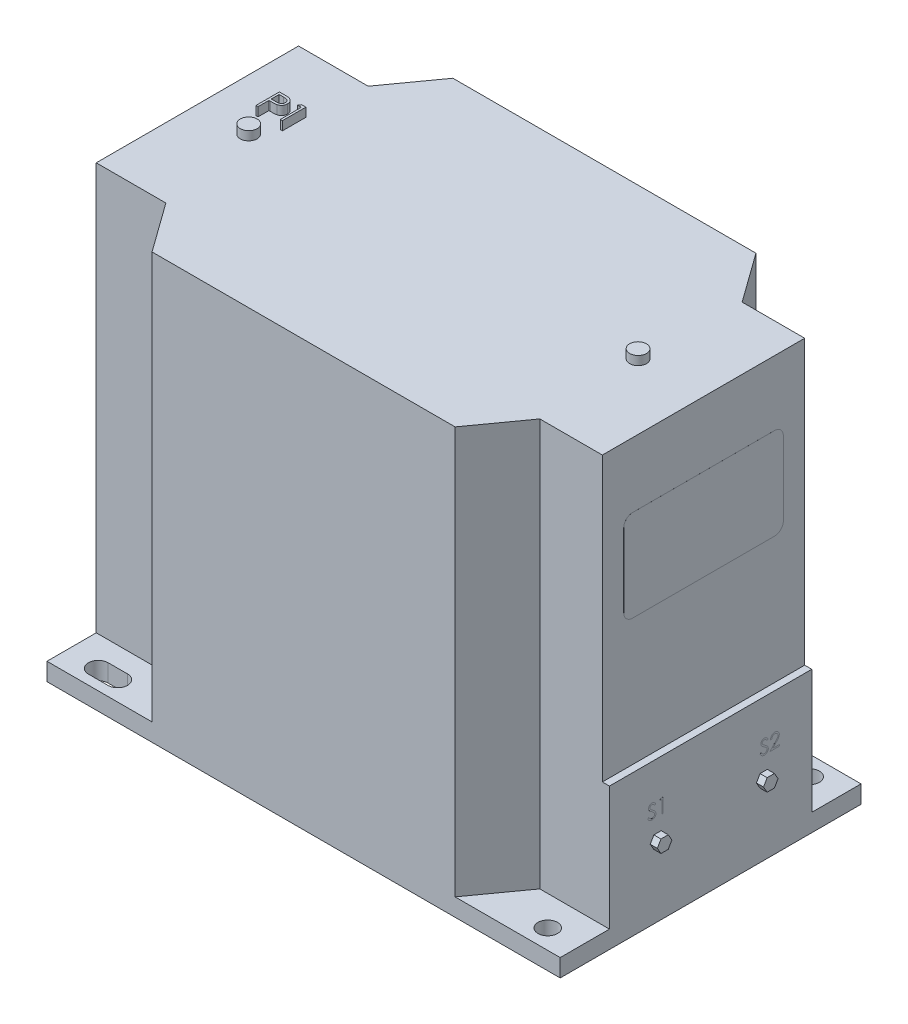
from build123d import *

# Parameters (mm, degrees)
CROQUIS1_W               = 290
CROQUIS1_H               = 170
SALIENTE_EXTRUIR1_DEPTH  = 240
CROQUIS2_R               = 5.5
CORTAR_EXTRUIR1_DEPTH    = 230
CROQUIS3_R               = 5.5
CORTAR_EXTRUIR3_DEPTH    = 309
CROQUIS4_W               = 114.318282822
CROQUIS4_H               = 160
CORTAR_EXTRUIR4_DEPTH    = 4
SALIENTE_EXTRUIR2_DEPTH  = 4
SALIENTE_EXTRUIR3_DEPTH  = 4
SALIENTE_EXTRUIR5_DEPTH  = 4
SALIENTE_EXTRUIR6_DEPTH  = 0.01
SALIENTE_EXTRUIR7_DEPTH  = 0.01
SALIENTE_EXTRUIR8_DEPTH  = 0.01
CROQUIS11_R              = 4.75
SALIENTE_EXTRUIR9_DEPTH  = 5
CROQUIS12_W              = 19.477537379
CROQUIS12_H              = 1.947753737
CROQUIS12_W_2            = 14.751875946
CROQUIS12_H_2            = 1.829107359
CROQUIS12_W_3            = 5.2253802
CROQUIS12_H_3            = 1.246064316
CROQUIS12_W_4            = 1.909821467
CROQUIS12_H_4            = 22.488415391
CROQUIS12_W_5            = 10.038203482
CROQUIS12_H_5            = 1.679080429
SALIENTE_EXTRUIR10_DEPTH = 0.1


with BuildPart() as part:
    # Croquis1 → Saliente-Extruir1 (new body)
    with BuildSketch(Plane(origin=(0, 0, 0), x_dir=(1, 0, 0), z_dir=(0, 1, 0))):
        Rectangle(CROQUIS1_W, CROQUIS1_H)
    extrude(amount=SALIENTE_EXTRUIR1_DEPTH)

    # Croquis2 → Cortar-Extruir1 (cut)
    with BuildSketch(Plane(origin=(0, 240, 0), x_dir=(1, 0, 0), z_dir=(0, 1, 0))):
        Polygon((-105.653068474, -57.159141411), (-145, -57.159141411), (-145, -85), (-85.626113794, -85), align=None)
        with BuildLine():
            Line((-116, -79.5), (-127, -79.5))
            ThreePointArc((-127, -79.5), (-132.5, -74), (-127, -68.5))
            Line((-127, -68.5), (-116, -68.5))
            ThreePointArc((-116, -68.5), (-110.5, -74), (-116, -79.5))
        make_face(mode=Mode.SUBTRACT)
        Polygon((-145, 85), (-145, 57.159141411), (-105.653068474, 57.159141411), (-85.626113794, 85), align=None)
        with BuildLine():
            ThreePointArc((-127, 68.5), (-132.5, 74), (-127, 79.5))
            Line((-127, 79.5), (-116, 79.5))
            ThreePointArc((-116, 79.5), (-110.5, 74), (-116, 68.5))
            Line((-116, 68.5), (-127, 68.5))
        make_face(mode=Mode.SUBTRACT)
        Polygon((145, 85), (85.626113794, 85), (105.653068474, 57.159141411), (145, 57.159141411), align=None)
        with Locations((127, 74)):
            Circle(CROQUIS2_R, mode=Mode.SUBTRACT)
        Polygon((105.653068474, -57.159141411), (85.626113794, -85), (145, -85), (145, -57.159141411), align=None)
        with Locations((127, -74)):
            Circle(CROQUIS2_R, mode=Mode.SUBTRACT)
    extrude(amount=-CORTAR_EXTRUIR1_DEPTH, mode=Mode.SUBTRACT)

    # Croquis3 → Cortar-Extruir3 (cut)
    with BuildSketch(Plane(origin=(0, 240, 0), x_dir=(1, 0, 0), z_dir=(0, 1, 0))):
        with Locations((127, 74)):
            Circle(CROQUIS3_R)
        with Locations((127, -74)):
            Circle(CROQUIS3_R)
        with BuildLine():
            Line((-127, 79.5), (-116, 79.5))
            ThreePointArc((-116, 79.5), (-110.5, 74), (-116, 68.5))
            Line((-116, 68.5), (-127, 68.5))
            ThreePointArc((-127, 68.5), (-132.5, 74), (-127, 79.5))
        make_face()
        with BuildLine():
            Line((-127, -68.426195021), (-116, -68.426195021))
            ThreePointArc((-116, -68.426195021), (-110.426195021, -74), (-116, -79.573804979))
            Line((-116, -79.573804979), (-127, -79.573804979))
            ThreePointArc((-127, -79.573804979), (-132.573804979, -74), (-127, -68.426195021))
        make_face()
    extrude(amount=-CORTAR_EXTRUIR3_DEPTH, mode=Mode.SUBTRACT)

    # Croquis4 → Cortar-Extruir4 (cut)
    with BuildSketch(Plane(origin=(145, 0, 0), x_dir=(0, 0, -1), z_dir=(1, 0, 0))):
        with Locations((0, 160)):
            Rectangle(CROQUIS4_W, CROQUIS4_H)
    extrude(amount=-CORTAR_EXTRUIR4_DEPTH, mode=Mode.SUBTRACT)

    # Croquis5 → Saliente-Extruir2 (add)
    with BuildSketch(Plane.ZY.offset(145)):
        Polygon((43.413866741, 29.419642397), (40.989340839, 33.619044445), (36.140289034, 33.619044445), (33.715763131, 29.419642397), (36.140289034, 25.220240349), (40.989340839, 25.220240349), align=None)
    extrude(amount=SALIENTE_EXTRUIR2_DEPTH)

    # Croquis6 → Saliente-Extruir3 (add)
    with BuildSketch(Plane.ZY.offset(145)):
        Polygon((43.413866741, 74.385865647), (40.989340839, 78.585267695), (36.140289034, 78.585267695), (33.715763131, 74.385865647), (36.140289034, 70.186463599), (40.989340839, 70.186463599), align=None)
    extrude(amount=SALIENTE_EXTRUIR3_DEPTH)

    # Croquis7 → Saliente-Extruir5 (add)
    with BuildSketch(Plane(origin=(145, 0, 0), x_dir=(0, 0, -1), z_dir=(1, 0, 0))):
        Polygon((-27.944874359, 36.440417974), (-32.055125641, 36.440417974), (-34.110251282, 40), (-32.055125641, 43.559582026), (-27.944874359, 43.559582026), (-25.889748718, 40), align=None)
        Polygon((34.110251282, 40), (32.055125641, 43.559582026), (27.944874359, 43.559582026), (25.889748718, 40), (27.944874359, 36.440417974), (32.055125641, 36.440417974), align=None)
    extrude(amount=SALIENTE_EXTRUIR5_DEPTH)

    # Croquis8 → Saliente-Extruir6 (add)
    with BuildSketch(Plane(origin=(145, 0, 0), x_dir=(0, 0, -1), z_dir=(1, 0, 0))):
        with BuildLine():
            Line((-35.585423462, 53.072879107), (-34.914424864, 53.475160256))
            add(Edge.make_bspline(
                [(-34.914424864, 53.475160256), (-34.852017433, 53.370692812), (-34.732447204, 53.17053722), (-34.532986086, 52.900077021), (-34.326309663, 52.67020213), (-34.110887424, 52.482249823), (-33.888034292, 52.33427467), (-33.656295455, 52.229494608), (-33.416451849, 52.164144093), (-33.253225504, 52.156206397), (-33.171736563, 52.15224359)],
                knots=[0, 0, 0, 0, 0.0003649, 0.000699135, 0.001006425, 0.001290478, 0.001554646, 0.001805858, 0.002050756, 0.002294909, 0.002294909, 0.002294909, 0.002294909], degree=3))
            add(Edge.make_bspline(
                [(-33.171736563, 52.15224359), (-33.102143147, 52.154181865), (-32.964174037, 52.1580245), (-32.761059665, 52.194947033), (-32.563797363, 52.251670968), (-32.376452774, 52.332907724), (-32.201610934, 52.431193218), (-32.048288607, 52.549906871), (-31.915741172, 52.682817373), (-31.80731693, 52.831095893), (-31.72413185, 52.990565141), (-31.660196266, 53.154249888), (-31.624715474, 53.324721462), (-31.619370694, 53.439498762), (-31.616673462, 53.497420873)],
                knots=[0, 0, 0, 0, 0.000208593, 0.000413536, 0.000617316, 0.000823176, 0.001024736, 0.001217466, 0.001402984, 0.001586171, 0.001766127, 0.001941248, 0.002111828, 0.002285609, 0.002285609, 0.002285609, 0.002285609], degree=3))
            add(Edge.make_bspline(
                [(-31.616673462, 53.497420873), (-31.620016988, 53.563508158), (-31.626813888, 53.697853949), (-31.684262066, 53.896063876), (-31.774634465, 54.092216669), (-31.858006889, 54.213549896), (-31.901291351, 54.276542468)],
                knots=[0, 0, 0, 0, 0.00019794, 0.000402383, 0.000614384, 0.000843289, 0.000843289, 0.000843289, 0.000843289], degree=3))
            add(Edge.make_bspline(
                [(-31.901291351, 54.276542468), (-31.936830065, 54.3220058), (-32.01143915, 54.417450379), (-32.139703509, 54.559520824), (-32.290212376, 54.706066167), (-32.45781508, 54.862682242), (-32.648616907, 55.022084924), (-32.856641806, 55.191875483), (-33.087200914, 55.365596917), (-33.248897987, 55.482102556), (-33.332331014, 55.542217548)],
                knots=[0, 0, 0, 0, 0.000173081, 0.000363362, 0.000573615, 0.000803155, 0.001051334, 0.001319279, 0.001608672, 0.001917177, 0.001917177, 0.001917177, 0.001917177], degree=3))
            add(Edge.make_bspline(
                [(-33.332331014, 55.542217548), (-33.415842577, 55.601700238), (-33.575510326, 55.715426611), (-33.798800325, 55.884210255), (-33.998472589, 56.038524031), (-34.173639645, 56.17982063), (-34.324224445, 56.308119215), (-34.451413609, 56.422187756), (-34.551967122, 56.525111189), (-34.607882457, 56.591879946), (-34.632987064, 56.621857472)],
                knots=[0, 0, 0, 0, 0.000307574, 0.000588058, 0.000839637, 0.001064621, 0.001263128, 0.001433085, 0.001577017, 0.001694292, 0.001694292, 0.001694292, 0.001694292], degree=3))
            add(Edge.make_bspline(
                [(-34.632987064, 56.621857472), (-34.668076586, 56.668577681), (-34.737084841, 56.760459241), (-34.828175603, 56.904070972), (-34.905598347, 57.051080877), (-34.966291493, 57.201883999), (-35.017400418, 57.354363212), (-35.05177644, 57.510508002), (-35.073301572, 57.669617726), (-35.075505899, 57.7766912), (-35.07660936, 57.830290966)],
                knots=[0, 0, 0, 0, 0.000175237, 0.000344627, 0.000509624, 0.000672912, 0.000831805, 0.000991507, 0.00115185, 0.00131257, 0.00131257, 0.00131257, 0.00131257], degree=3))
            add(Edge.make_bspline(
                [(-35.07660936, 57.830290966), (-35.073649332, 57.914269204), (-35.067792545, 58.080430706), (-35.018261372, 58.323161339), (-34.940081774, 58.554905535), (-34.830555868, 58.773368971), (-34.689365085, 58.972863249), (-34.525975108, 59.155683121), (-34.331366916, 59.309372584), (-34.117842217, 59.443657074), (-33.884125087, 59.548763012), (-33.639217145, 59.62804952), (-33.382729143, 59.672974087), (-33.209004177, 59.679421071), (-33.120855153, 59.682692308)],
                knots=[0, 0, 0, 0, 0.00025173, 0.000498079, 0.000739938, 0.000983843, 0.001228213, 0.001471329, 0.001716675, 0.001969492, 0.002226362, 0.002483325, 0.002740032, 0.003004458, 0.003004458, 0.003004458, 0.003004458], degree=3))
            add(Edge.make_bspline(
                [(-33.120855153, 59.682692308), (-33.027319425, 59.679466164), (-32.841306717, 59.673050394), (-32.567691532, 59.617266706), (-32.304255621, 59.524963397), (-32.092339646, 59.420214119), (-31.92648499, 59.315594659), (-31.8000004, 59.2202997), (-31.671826896, 59.110591864), (-31.540930593, 58.986178931), (-31.409529454, 58.845919335), (-31.275672696, 58.690773666), (-31.139047301, 58.521690048), (-31.051154547, 58.400984484), (-31.006096539, 58.339105068)],
                knots=[0, 0, 0, 0, 0.000280394, 0.000557614, 0.000833682, 0.001115986, 0.001264644, 0.001421423, 0.001590611, 0.00177056, 0.001962903, 0.002166931, 0.002385208, 0.002614814, 0.002614814, 0.002614814, 0.002614814], degree=3))
            Line((-31.006096539, 58.339105068), (-31.650064388, 57.850961538))
            add(Edge.make_bspline(
                [(-31.650064388, 57.850961538), (-31.688948913, 57.901055533), (-31.763831417, 57.997524854), (-31.877517932, 58.132624087), (-31.984671116, 58.256032889), (-32.090240773, 58.363223447), (-32.18865133, 58.460065785), (-32.284166765, 58.542978091), (-32.375412526, 58.612772745), (-32.490431234, 58.687257247), (-32.634933916, 58.761090746), (-32.816327418, 58.823568119), (-33.005889149, 58.861112635), (-33.13499742, 58.866076719), (-33.200357356, 58.868589744)],
                knots=[0, 0, 0, 0, 0.000190221, 0.000366322, 0.000529664, 0.000680341, 0.000817528, 0.000943773, 0.00105953, 0.001161851, 0.001354561, 0.001544636, 0.001735792, 0.001931781, 0.001931781, 0.001931781, 0.001931781], degree=3))
            add(Edge.make_bspline(
                [(-33.200357356, 58.868589744), (-33.282355184, 58.865841781), (-33.44048027, 58.860542595), (-33.664975984, 58.802666914), (-33.867028278, 58.711540195), (-34.04063856, 58.583825869), (-34.185184919, 58.43251219), (-34.289745513, 58.258388715), (-34.352678921, 58.066114337), (-34.36035852, 57.93198951), (-34.364269616, 57.863681891)],
                knots=[0, 0, 0, 0, 0.000245491, 0.000473406, 0.000690404, 0.000906674, 0.001115908, 0.001314154, 0.001511268, 0.001715841, 0.001715841, 0.001715841, 0.001715841], degree=3))
            add(Edge.make_bspline(
                [(-34.364269616, 57.863681891), (-34.363378061, 57.821156216), (-34.361593493, 57.73603533), (-34.33670422, 57.610279426), (-34.304728956, 57.48484121), (-34.254059059, 57.360284638), (-34.184106317, 57.23443136), (-34.092246364, 57.105114205), (-33.97655546, 56.971193366), (-33.887934378, 56.884090929), (-33.841145117, 56.838103466)],
                knots=[0, 0, 0, 0, 0.000127362, 0.000254933, 0.000383373, 0.000515356, 0.000656977, 0.000814464, 0.000990378, 0.001187139, 0.001187139, 0.001187139, 0.001187139], degree=3))
            add(Edge.make_bspline(
                [(-33.841145117, 56.838103466), (-33.823770219, 56.822598068), (-33.782491438, 56.785760792), (-33.707026392, 56.725453298), (-33.607370403, 56.651061297), (-33.486125768, 56.559015061), (-33.34105693, 56.452241031), (-33.172147937, 56.332104446), (-32.981281603, 56.19470528), (-32.84584083, 56.098644429), (-32.774225545, 56.047851563)],
                knots=[0, 0, 0, 0, 6.9853e-05, 0.000165956, 0.000289663, 0.000442943, 0.000622625, 0.000830015, 0.001064761, 0.001328157, 0.001328157, 0.001328157, 0.001328157], degree=3))
            add(Edge.make_bspline(
                [(-32.774225545, 56.047851563), (-32.688078921, 55.985164908), (-32.521267921, 55.863780889), (-32.283919481, 55.681409615), (-32.068713881, 55.503047711), (-31.874895544, 55.329834209), (-31.700549698, 55.163082998), (-31.547610582, 55.000787929), (-31.414519842, 54.844111719), (-31.2712384, 54.643241771), (-31.124830488, 54.396541812), (-30.99909707, 54.094285807), (-30.919816532, 53.790854865), (-30.909448988, 53.586913647), (-30.904333719, 53.486290565)],
                knots=[0, 0, 0, 0, 0.000319615, 0.00061889, 0.000897801, 0.001157932, 0.001398581, 0.001621301, 0.001826718, 0.0020147, 0.002361038, 0.002684673, 0.002994344, 0.003295938, 0.003295938, 0.003295938, 0.003295938], degree=3))
            add(Edge.make_bspline(
                [(-30.904333719, 53.486290565), (-30.905824014, 53.415128915), (-30.908775664, 53.274187528), (-30.942704879, 53.06723405), (-30.992415549, 52.866231899), (-31.067339276, 52.673665626), (-31.158786438, 52.486012325), (-31.274824179, 52.308194408), (-31.409325535, 52.136276326), (-31.563616395, 51.974842336), (-31.732449066, 51.826646499), (-31.910892445, 51.694818092), (-32.0992386, 51.584898858), (-32.296465782, 51.495203199), (-32.502619296, 51.4250504), (-32.717629806, 51.374221215), (-32.941851733, 51.343025227), (-33.094252825, 51.339787268), (-33.171736563, 51.338141026)],
                knots=[0, 0, 0, 0, 0.000213279, 0.000422417, 0.000627582, 0.000833411, 0.001041051, 0.00125276, 0.001469058, 0.001695119, 0.001921581, 0.002142294, 0.002359642, 0.002574533, 0.002791252, 0.003011856, 0.003236503, 0.003468846, 0.003468846, 0.003468846, 0.003468846], degree=3))
            add(Edge.make_bspline(
                [(-33.171736563, 51.338141026), (-33.231688144, 51.339300312), (-33.350836279, 51.341604286), (-33.527070282, 51.361972547), (-33.699743994, 51.390790443), (-33.866690669, 51.436542351), (-34.030061227, 51.492052639), (-34.189145134, 51.560402072), (-34.344019489, 51.642310725), (-34.495552221, 51.735961941), (-34.643357939, 51.844950041), (-34.786050303, 51.971889934), (-34.928311135, 52.113280633), (-35.06594148, 52.272961732), (-35.201725218, 52.448353456), (-35.332985182, 52.641096782), (-35.462438364, 52.850141853), (-35.543662728, 52.997246601), (-35.585423462, 53.072879107)],
                knots=[0, 0, 0, 0, 0.000179788, 0.000357311, 0.000531673, 0.000704462, 0.000875929, 0.00104901, 0.001223263, 0.001401078, 0.001582983, 0.001773397, 0.001973528, 0.002184286, 0.002405325, 0.002638633, 0.002883531, 0.003142684, 0.003142684, 0.003142684, 0.003142684], degree=3))
        make_face()
        Polygon((-28.301431575, 59.479166667), (-26.833820898, 59.479166667), (-26.833820898, 51.541666667), (-27.546160642, 51.541666667), (-27.546160642, 58.665064103), (-28.767314488, 58.665064103), align=None)
        with BuildLine():
            Line((27.914576538, 53.072879107), (28.585575136, 53.475160256))
            add(Edge.make_bspline(
                [(28.585575136, 53.475160256), (28.647982567, 53.370692812), (28.767552796, 53.17053722), (28.967013914, 52.900077021), (29.173690337, 52.67020213), (29.389112576, 52.482249823), (29.611965708, 52.33427467), (29.843704545, 52.229494608), (30.083548151, 52.164144093), (30.246774496, 52.156206397), (30.328263437, 52.15224359)],
                knots=[0, 0, 0, 0, 0.0003649, 0.000699135, 0.001006425, 0.001290478, 0.001554646, 0.001805858, 0.002050756, 0.002294909, 0.002294909, 0.002294909, 0.002294909], degree=3))
            add(Edge.make_bspline(
                [(30.328263437, 52.15224359), (30.397856853, 52.154181865), (30.535825963, 52.1580245), (30.738940335, 52.194947033), (30.936202637, 52.251670968), (31.123547226, 52.332907724), (31.298389066, 52.431193218), (31.451711393, 52.549906871), (31.584258828, 52.682817373), (31.69268307, 52.831095893), (31.77586815, 52.990565141), (31.839803734, 53.154249888), (31.875284526, 53.324721462), (31.880629306, 53.439498762), (31.883326538, 53.497420873)],
                knots=[0, 0, 0, 0, 0.000208593, 0.000413536, 0.000617316, 0.000823176, 0.001024736, 0.001217466, 0.001402984, 0.001586171, 0.001766127, 0.001941248, 0.002111828, 0.002285609, 0.002285609, 0.002285609, 0.002285609], degree=3))
            add(Edge.make_bspline(
                [(31.883326538, 53.497420873), (31.879983012, 53.563508158), (31.873186112, 53.697853949), (31.815737934, 53.896063876), (31.725365535, 54.092216669), (31.641993111, 54.213549896), (31.598708649, 54.276542468)],
                knots=[0, 0, 0, 0, 0.00019794, 0.000402383, 0.000614384, 0.000843289, 0.000843289, 0.000843289, 0.000843289], degree=3))
            add(Edge.make_bspline(
                [(31.598708649, 54.276542468), (31.563169935, 54.3220058), (31.48856085, 54.417450379), (31.360296491, 54.559520824), (31.209787624, 54.706066167), (31.04218492, 54.862682242), (30.851383093, 55.022084924), (30.643358194, 55.191875483), (30.412799086, 55.365596917), (30.251102013, 55.482102556), (30.167668986, 55.542217548)],
                knots=[0, 0, 0, 0, 0.000173081, 0.000363362, 0.000573615, 0.000803155, 0.001051334, 0.001319279, 0.001608672, 0.001917177, 0.001917177, 0.001917177, 0.001917177], degree=3))
            add(Edge.make_bspline(
                [(30.167668986, 55.542217548), (30.084157423, 55.601700238), (29.924489674, 55.715426611), (29.701199675, 55.884210255), (29.501527411, 56.038524031), (29.326360355, 56.17982063), (29.175775555, 56.308119215), (29.048586391, 56.422187756), (28.948032878, 56.525111189), (28.892117543, 56.591879946), (28.867012936, 56.621857472)],
                knots=[0, 0, 0, 0, 0.000307574, 0.000588058, 0.000839637, 0.001064621, 0.001263128, 0.001433085, 0.001577017, 0.001694292, 0.001694292, 0.001694292, 0.001694292], degree=3))
            add(Edge.make_bspline(
                [(28.867012936, 56.621857472), (28.831923414, 56.668577681), (28.762915159, 56.760459241), (28.671824397, 56.904070972), (28.594401653, 57.051080877), (28.533708507, 57.201883999), (28.482599582, 57.354363212), (28.44822356, 57.510508002), (28.426698428, 57.669617726), (28.424494101, 57.7766912), (28.42339064, 57.830290966)],
                knots=[0, 0, 0, 0, 0.000175237, 0.000344627, 0.000509624, 0.000672912, 0.000831805, 0.000991507, 0.00115185, 0.00131257, 0.00131257, 0.00131257, 0.00131257], degree=3))
            add(Edge.make_bspline(
                [(28.42339064, 57.830290966), (28.426350668, 57.914269204), (28.432207455, 58.080430706), (28.481738628, 58.323161339), (28.559918226, 58.554905535), (28.669444132, 58.773368971), (28.810634915, 58.972863249), (28.974024892, 59.155683121), (29.168633084, 59.309372584), (29.382157783, 59.443657074), (29.615874913, 59.548763012), (29.860782855, 59.62804952), (30.117270857, 59.672974087), (30.290995823, 59.679421071), (30.379144847, 59.682692308)],
                knots=[0, 0, 0, 0, 0.00025173, 0.000498079, 0.000739938, 0.000983843, 0.001228213, 0.001471329, 0.001716675, 0.001969492, 0.002226362, 0.002483325, 0.002740032, 0.003004458, 0.003004458, 0.003004458, 0.003004458], degree=3))
            add(Edge.make_bspline(
                [(30.379144847, 59.682692308), (30.472680575, 59.679466164), (30.658693283, 59.673050394), (30.932308468, 59.617266706), (31.195744379, 59.524963397), (31.407660354, 59.420214119), (31.57351501, 59.315594659), (31.6999996, 59.2202997), (31.828173104, 59.110591864), (31.959069407, 58.986178931), (32.090470546, 58.845919335), (32.224327304, 58.690773666), (32.360952699, 58.521690048), (32.448845453, 58.400984484), (32.493903461, 58.339105068)],
                knots=[0, 0, 0, 0, 0.000280394, 0.000557614, 0.000833682, 0.001115986, 0.001264644, 0.001421423, 0.001590611, 0.00177056, 0.001962903, 0.002166931, 0.002385208, 0.002614814, 0.002614814, 0.002614814, 0.002614814], degree=3))
            Line((32.493903461, 58.339105068), (31.849935612, 57.850961538))
            add(Edge.make_bspline(
                [(31.849935612, 57.850961538), (31.811051087, 57.901055533), (31.736168583, 57.997524854), (31.622482068, 58.132624087), (31.515328884, 58.256032889), (31.409759227, 58.363223447), (31.31134867, 58.460065785), (31.215833235, 58.542978091), (31.124587474, 58.612772745), (31.009568766, 58.687257247), (30.865066084, 58.761090746), (30.683672582, 58.823568119), (30.494110851, 58.861112635), (30.36500258, 58.866076719), (30.299642644, 58.868589744)],
                knots=[0, 0, 0, 0, 0.000190221, 0.000366322, 0.000529664, 0.000680341, 0.000817528, 0.000943773, 0.00105953, 0.001161851, 0.001354561, 0.001544636, 0.001735792, 0.001931781, 0.001931781, 0.001931781, 0.001931781], degree=3))
            add(Edge.make_bspline(
                [(30.299642644, 58.868589744), (30.217644816, 58.865841781), (30.05951973, 58.860542595), (29.835024016, 58.802666914), (29.632971722, 58.711540195), (29.45936144, 58.583825869), (29.314815081, 58.43251219), (29.210254487, 58.258388715), (29.147321079, 58.066114337), (29.13964148, 57.93198951), (29.135730384, 57.863681891)],
                knots=[0, 0, 0, 0, 0.000245491, 0.000473406, 0.000690404, 0.000906674, 0.001115908, 0.001314154, 0.001511268, 0.001715841, 0.001715841, 0.001715841, 0.001715841], degree=3))
            add(Edge.make_bspline(
                [(29.135730384, 57.863681891), (29.136621939, 57.821156216), (29.138406507, 57.73603533), (29.16329578, 57.610279426), (29.195271044, 57.48484121), (29.245940941, 57.360284638), (29.315893683, 57.23443136), (29.407753636, 57.105114205), (29.52344454, 56.971193366), (29.612065622, 56.884090929), (29.658854883, 56.838103466)],
                knots=[0, 0, 0, 0, 0.000127362, 0.000254933, 0.000383373, 0.000515356, 0.000656977, 0.000814464, 0.000990378, 0.001187139, 0.001187139, 0.001187139, 0.001187139], degree=3))
            add(Edge.make_bspline(
                [(29.658854883, 56.838103466), (29.676229781, 56.822598068), (29.717508562, 56.785760792), (29.792973608, 56.725453298), (29.892629597, 56.651061297), (30.013874232, 56.559015061), (30.15894307, 56.452241031), (30.327852063, 56.332104446), (30.518718397, 56.19470528), (30.65415917, 56.098644429), (30.725774455, 56.047851563)],
                knots=[0, 0, 0, 0, 6.9853e-05, 0.000165956, 0.000289663, 0.000442943, 0.000622625, 0.000830015, 0.001064761, 0.001328157, 0.001328157, 0.001328157, 0.001328157], degree=3))
            add(Edge.make_bspline(
                [(30.725774455, 56.047851563), (30.811921079, 55.985164908), (30.978732079, 55.863780889), (31.216080519, 55.681409615), (31.431286119, 55.503047711), (31.625104456, 55.329834209), (31.799450302, 55.163082998), (31.952389418, 55.000787929), (32.085480158, 54.844111719), (32.2287616, 54.643241771), (32.375169512, 54.396541812), (32.50090293, 54.094285807), (32.580183468, 53.790854865), (32.590551012, 53.586913647), (32.595666281, 53.486290565)],
                knots=[0, 0, 0, 0, 0.000319615, 0.00061889, 0.000897801, 0.001157932, 0.001398581, 0.001621301, 0.001826718, 0.0020147, 0.002361038, 0.002684673, 0.002994344, 0.003295938, 0.003295938, 0.003295938, 0.003295938], degree=3))
            add(Edge.make_bspline(
                [(32.595666281, 53.486290565), (32.594175986, 53.415128915), (32.591224336, 53.274187528), (32.557295121, 53.06723405), (32.507584451, 52.866231899), (32.432660724, 52.673665626), (32.341213562, 52.486012325), (32.225175821, 52.308194408), (32.090674465, 52.136276326), (31.936383605, 51.974842336), (31.767550934, 51.826646499), (31.589107555, 51.694818092), (31.4007614, 51.584898858), (31.203534218, 51.495203199), (30.997380704, 51.4250504), (30.782370194, 51.374221215), (30.558148267, 51.343025227), (30.405747175, 51.339787268), (30.328263437, 51.338141026)],
                knots=[0, 0, 0, 0, 0.000213279, 0.000422417, 0.000627582, 0.000833411, 0.001041051, 0.00125276, 0.001469058, 0.001695119, 0.001921581, 0.002142294, 0.002359642, 0.002574533, 0.002791252, 0.003011856, 0.003236503, 0.003468846, 0.003468846, 0.003468846, 0.003468846], degree=3))
            add(Edge.make_bspline(
                [(30.328263437, 51.338141026), (30.268311856, 51.339300312), (30.149163721, 51.341604286), (29.972929718, 51.361972547), (29.800256006, 51.390790443), (29.633309331, 51.436542351), (29.469938773, 51.492052639), (29.310854866, 51.560402072), (29.155980511, 51.642310725), (29.004447779, 51.735961941), (28.856642061, 51.844950041), (28.713949697, 51.971889934), (28.571688865, 52.113280633), (28.43405852, 52.272961732), (28.298274782, 52.448353456), (28.167014818, 52.641096782), (28.037561636, 52.850141853), (27.956337272, 52.997246601), (27.914576538, 53.072879107)],
                knots=[0, 0, 0, 0, 0.000179788, 0.000357311, 0.000531673, 0.000704462, 0.000875929, 0.00104901, 0.001223263, 0.001401078, 0.001582983, 0.001773397, 0.001973528, 0.002184286, 0.002405325, 0.002638633, 0.002883531, 0.003142684, 0.003142684, 0.003142684, 0.003142684], degree=3))
        make_face()
        with BuildLine():
            Line((34.529159871, 57.036858974), (33.816820128, 57.036858974))
            add(Edge.make_bspline(
                [(33.816820128, 57.036858974), (33.821462778, 57.131362595), (33.83058082, 57.31696519), (33.873280691, 57.587574764), (33.934378751, 57.846234754), (34.020764728, 58.090868309), (34.128048607, 58.323638461), (34.256704205, 58.543620639), (34.409090259, 58.749975657), (34.581916245, 58.940790533), (34.769623695, 59.115840917), (34.972156807, 59.267005486), (35.184983923, 59.394725919), (35.407459345, 59.501499449), (35.642093123, 59.581645171), (35.886756033, 59.641112104), (36.142523003, 59.676890602), (36.316785196, 59.680736402), (36.405411874, 59.682692308)],
                knots=[0, 0, 0, 0, 0.00028367, 0.000557121, 0.000820522, 0.001080006, 0.001333985, 0.001588417, 0.001843152, 0.0021021, 0.00235977, 0.002611952, 0.002858736, 0.003103402, 0.003350806, 0.003601095, 0.003857896, 0.004123666, 0.004123666, 0.004123666, 0.004123666], degree=3))
            add(Edge.make_bspline(
                [(36.405411874, 59.682692308), (36.492447864, 59.680654737), (36.663470474, 59.676650983), (36.9130754, 59.642267934), (37.150695335, 59.588416325), (37.375865806, 59.51286172), (37.586790274, 59.411297036), (37.78505325, 59.289291904), (37.973015089, 59.148186215), (38.142212616, 58.982057031), (38.297579153, 58.804705195), (38.431614624, 58.615366556), (38.546398048, 58.419810855), (38.642073679, 58.216546897), (38.712504566, 58.003660815), (38.765976573, 57.78425198), (38.796201244, 57.556049284), (38.800839972, 57.401593345), (38.803198333, 57.323066907)],
                knots=[0, 0, 0, 0, 0.000261005, 0.000512865, 0.000754321, 0.000991152, 0.001223718, 0.001454969, 0.001688711, 0.001927112, 0.002164944, 0.002395254, 0.002621873, 0.002844536, 0.003067789, 0.003293401, 0.0035212, 0.003756789, 0.003756789, 0.003756789, 0.003756789], degree=3))
            add(Edge.make_bspline(
                [(38.803198333, 57.323066907), (38.799358255, 57.212513782), (38.791745486, 56.993347583), (38.726625382, 56.671278162), (38.624919901, 56.359235944), (38.50246161, 56.108099563), (38.378925889, 55.905730746), (38.267602434, 55.739114219), (38.137280452, 55.559714318), (37.986063144, 55.368131785), (37.817078595, 55.162865982), (37.628796188, 54.94404091), (37.419873292, 54.713917432), (37.273237049, 54.556742229), (37.197253822, 54.475297977)],
                knots=[0, 0, 0, 0, 0.000331374, 0.000656934, 0.000981755, 0.001313861, 0.001492201, 0.001692855, 0.001914853, 0.002157229, 0.002424948, 0.002712447, 0.003023161, 0.003357316, 0.003357316, 0.003357316, 0.003357316], degree=3))
            Line((37.197253822, 54.475297977), (35.211288777, 52.355769231))
            Line((35.211288777, 52.355769231), (38.904961153, 52.355769231))
            Line((38.904961153, 52.355769231), (38.904961153, 51.541666667))
            Line((38.904961153, 51.541666667), (33.511531666, 51.541666667))
            Line((33.511531666, 51.541666667), (36.589856987, 54.826697716))
            add(Edge.make_bspline(
                [(36.589856987, 54.826697716), (36.664804873, 54.904934947), (36.808764424, 55.055212656), (37.012378482, 55.274611869), (37.195256187, 55.478151006), (37.358581346, 55.6654455), (37.498810903, 55.839234949), (37.623253286, 55.993890794), (37.722960965, 56.136208923), (37.831172666, 56.301174243), (37.935979374, 56.502587891), (38.026041325, 56.748726794), (38.080957142, 57.002108242), (38.087544893, 57.173336076), (38.090858589, 57.259465144)],
                knots=[0, 0, 0, 0, 0.000325027, 0.00062431, 0.000897913, 0.001145919, 0.00136967, 0.001567839, 0.00174122, 0.001890735, 0.00215956, 0.002420114, 0.002675206, 0.002933386, 0.002933386, 0.002933386, 0.002933386], degree=3))
            add(Edge.make_bspline(
                [(38.090858589, 57.259465144), (38.089416816, 57.313624744), (38.086575359, 57.420362916), (38.061498081, 57.576858119), (38.02360104, 57.727817608), (37.969296616, 57.873705726), (37.897617045, 58.013055687), (37.810364915, 58.146037115), (37.709694593, 58.27459959), (37.59323725, 58.395143676), (37.465303982, 58.505545696), (37.330152737, 58.603344961), (37.187164108, 58.685076516), (37.036940974, 58.752076947), (36.879902141, 58.804635401), (36.71574388, 58.841053965), (36.544919772, 58.863919598), (36.428275951, 58.867013345), (36.368840861, 58.868589744)],
                knots=[0, 0, 0, 0, 0.000162379, 0.000320018, 0.000474277, 0.000628741, 0.000785898, 0.000943344, 0.001105256, 0.001275063, 0.001445287, 0.001611643, 0.001774744, 0.001938449, 0.002104379, 0.002270635, 0.00244222, 0.002620482, 0.002620482, 0.002620482, 0.002620482], degree=3))
            add(Edge.make_bspline(
                [(36.368840861, 58.868589744), (36.306767722, 58.866968153), (36.184866327, 58.863783616), (36.005889235, 58.841507217), (35.835151846, 58.803076472), (35.672224674, 58.750515085), (35.516832041, 58.683707305), (35.369729656, 58.600495669), (35.231247746, 58.501200962), (35.101125988, 58.388623272), (34.981238036, 58.263284247), (34.875903156, 58.123561653), (34.78386441, 57.972006621), (34.703561327, 57.809028087), (34.63834753, 57.633147193), (34.588515564, 57.444988291), (34.549084679, 57.245368372), (34.535911784, 57.107516483), (34.529159871, 57.036858974)],
                knots=[0, 0, 0, 0, 0.000186205, 0.000365676, 0.000540038, 0.000710499, 0.000878571, 0.001046604, 0.001216471, 0.001388938, 0.001562143, 0.001735779, 0.00191276, 0.002093382, 0.002280042, 0.002474444, 0.00267683, 0.002889646, 0.002889646, 0.002889646, 0.002889646], degree=3))
        make_face()
    extrude(amount=SALIENTE_EXTRUIR6_DEPTH)

    # Croquis9 → Saliente-Extruir7 (add)
    with BuildSketch(Plane.ZY.offset(145)):
        with BuildLine():
            Line((31.885683761, 114.9375), (34.480105669, 114.9375))
            add(Edge.make_bspline(
                [(34.480105669, 114.9375), (34.658551654, 114.937303845), (35.000462085, 114.936928002), (35.490754111, 114.925532981), (35.936046846, 114.910313043), (36.335380131, 114.889214816), (36.689982645, 114.864281275), (36.998249819, 114.829310769), (37.26260469, 114.792797152), (37.421001091, 114.755674574), (37.493239183, 114.738744491)],
                knots=[0, 0, 0, 0, 0.000535321, 0.0010257, 0.001471196, 0.001871918, 0.002225373, 0.002537339, 0.002802691, 0.003025171, 0.003025171, 0.003025171, 0.003025171], degree=3))
            add(Edge.make_bspline(
                [(37.493239183, 114.738744491), (37.58468498, 114.713715097), (37.765421769, 114.664246096), (38.025851307, 114.565164463), (38.273629235, 114.447681279), (38.509605661, 114.313787221), (38.730880796, 114.157737618), (38.940756011, 113.98585817), (39.137379151, 113.794180515), (39.319644531, 113.584854504), (39.487030521, 113.361394187), (39.631151644, 113.120463735), (39.75182896, 112.86611863), (39.855331206, 112.598535786), (39.929824472, 112.315468195), (39.985942218, 112.018882704), (40.021561286, 111.708811107), (40.024972755, 111.496918156), (40.026709402, 111.389051649)],
                knots=[0, 0, 0, 0, 0.0002843, 0.000561901, 0.000834549, 0.001106385, 0.001374724, 0.001645836, 0.001919449, 0.002197416, 0.002477798, 0.002755942, 0.003038048, 0.003321544, 0.003615331, 0.003914708, 0.004226674, 0.004550157, 0.004550157, 0.004550157, 0.004550157], degree=3))
            add(Edge.make_bspline(
                [(40.026709402, 111.389051649), (40.025116517, 111.280278505), (40.021999929, 111.067456501), (39.984594327, 110.756106975), (39.934209376, 110.458570202), (39.856735399, 110.17550591), (39.755265146, 109.908595111), (39.636232685, 109.653758907), (39.492663984, 109.415332766), (39.327696919, 109.192451102), (39.144183452, 108.984904707), (38.942900025, 108.794197597), (38.724659247, 108.621446079), (38.490154699, 108.466262876), (38.237100211, 108.332246581), (37.969333738, 108.21221153), (37.68452786, 108.111401271), (37.487441572, 108.058370979), (37.387236245, 108.031408587)],
                knots=[0, 0, 0, 0, 0.000326131, 0.000638098, 0.000939601, 0.001230832, 0.001516807, 0.00179538, 0.002073524, 0.0023502, 0.002626177, 0.002903613, 0.00318091, 0.003460213, 0.003745955, 0.004038976, 0.004339885, 0.004651119, 0.004651119, 0.004651119, 0.004651119], degree=3))
            add(Edge.make_bspline(
                [(37.387236245, 108.031408587), (37.304356143, 108.013783629), (37.122719581, 107.975157508), (36.823578935, 107.932036258), (36.475291315, 107.895230445), (36.078332103, 107.867633884), (35.633057611, 107.844008979), (35.139226966, 107.825230767), (34.595870781, 107.81491257), (34.216869353, 107.814380406), (34.018992889, 107.814102564)],
                knots=[0, 0, 0, 0, 0.000254145, 0.000556973, 0.000906109, 0.001304688, 0.001750538, 0.002243801, 0.00278717, 0.003380792, 0.003380792, 0.003380792, 0.003380792], degree=3))
            Line((34.018992889, 107.814102564), (33.072916667, 107.814102564))
            Line((33.072916667, 107.814102564), (33.072916667, 101.708333333))
            Line((33.072916667, 101.708333333), (31.885683761, 101.708333333))
            Line((31.885683761, 101.708333333), (31.885683761, 114.9375))
        make_face()
        with BuildLine():
            Line((33.072916667, 113.580662393), (33.072916667, 109.170940171))
            Line((33.072916667, 109.170940171), (35.389080863, 109.141789363))
            add(Edge.make_bspline(
                [(35.389080863, 109.141789363), (35.502171058, 109.141730914), (35.72048935, 109.14161808), (36.035858408, 109.156681276), (36.328447083, 109.174070194), (36.597356639, 109.199530381), (36.842708296, 109.235518468), (37.064911158, 109.271848548), (37.262242257, 109.324407508), (37.493182692, 109.395176252), (37.750521536, 109.515873936), (38.030479234, 109.691065485), (38.267737105, 109.914376495), (38.473047334, 110.165457881), (38.635977289, 110.444778995), (38.755251427, 110.74364075), (38.825332587, 111.058978157), (38.834729807, 111.27475773), (38.839476496, 111.383751502)],
                knots=[0, 0, 0, 0, 0.00033922, 0.000654857, 0.000946954, 0.001218558, 0.001464787, 0.001690914, 0.00189338, 0.002076926, 0.002414901, 0.00274275, 0.003063453, 0.003387521, 0.003712952, 0.004029378, 0.004349588, 0.004676418, 0.004676418, 0.004676418, 0.004676418], degree=3))
            add(Edge.make_bspline(
                [(38.839476496, 111.383751502), (38.834703993, 111.490108384), (38.825216847, 111.7015327), (38.754702126, 112.011392896), (38.636209184, 112.307105231), (38.471953603, 112.58292612), (38.27260469, 112.833104039), (38.040907768, 113.05042949), (37.777408238, 113.225136521), (37.532297365, 113.337899222), (37.314578596, 113.406748627), (37.1254697, 113.454921089), (36.911948401, 113.493382458), (36.673945187, 113.524525817), (36.413304773, 113.551186221), (36.127787928, 113.569276075), (35.818476241, 113.579864913), (35.603745809, 113.58039013), (35.492433727, 113.580662393)],
                knots=[0, 0, 0, 0, 0.000318902, 0.000633938, 0.000947901, 0.001271047, 0.001593454, 0.001904722, 0.002220036, 0.002537835, 0.002710477, 0.002904584, 0.00312289, 0.003360881, 0.003624573, 0.003908737, 0.004218977, 0.004552896, 0.004552896, 0.004552896, 0.004552896], degree=3))
            Line((35.492433727, 113.580662393), (33.072916667, 113.580662393))
        make_face(mode=Mode.SUBTRACT)
        with BuildLine():
            Line((43.249198718, 110.866987179), (42.061965812, 110.866987179))
            add(Edge.make_bspline(
                [(42.061965812, 110.866987179), (42.069703563, 111.024493214), (42.0849003, 111.333830873), (42.15606675, 111.784846829), (42.257896852, 112.215946812), (42.401873478, 112.623669403), (42.580679945, 113.011619657), (42.795105941, 113.378256621), (43.049082698, 113.72218165), (43.337126008, 114.040206444), (43.649971757, 114.331957084), (43.987526945, 114.583898031), (44.342238804, 114.79676542), (44.713031175, 114.974721305), (45.104087472, 115.108297508), (45.511858988, 115.207409062), (45.938137271, 115.267039893), (46.228574259, 115.273449559), (46.37628539, 115.276709402)],
                knots=[0, 0, 0, 0, 0.000472784, 0.000928535, 0.001367536, 0.00180001, 0.002223309, 0.002647362, 0.00307192, 0.0035035, 0.003932951, 0.004353253, 0.004764561, 0.005172336, 0.005584676, 0.006001825, 0.006429826, 0.006872777, 0.006872777, 0.006872777, 0.006872777], degree=3))
            add(Edge.make_bspline(
                [(46.37628539, 115.276709402), (46.521345372, 115.27331345), (46.806383056, 115.266640527), (47.222391265, 115.209335446), (47.618424492, 115.119582763), (47.993708609, 114.993658422), (48.345249389, 114.824383949), (48.675687682, 114.621042062), (48.988957413, 114.385865914), (49.270953292, 114.10898394), (49.52989752, 113.813397547), (49.753289973, 113.497833149), (49.94459568, 113.17190698), (50.104055065, 112.833133718), (50.221439876, 112.478323581), (50.310559888, 112.112642189), (50.360934339, 111.732304362), (50.368665553, 111.474877798), (50.372596154, 111.344000401)],
                knots=[0, 0, 0, 0, 0.000435008, 0.000854775, 0.001257202, 0.001651921, 0.00203953, 0.002424949, 0.002814519, 0.003211853, 0.003608241, 0.00399209, 0.004369788, 0.004740893, 0.005112981, 0.005489002, 0.005868666, 0.006261315, 0.006261315, 0.006261315, 0.006261315], degree=3))
            add(Edge.make_bspline(
                [(50.372596154, 111.344000401), (50.366196023, 111.159745193), (50.353508076, 110.794468194), (50.244974569, 110.257685826), (50.075465435, 109.737615463), (49.871368283, 109.319054827), (49.665475414, 108.981773466), (49.479936322, 108.704079254), (49.262733019, 108.405079418), (49.010704172, 108.085775197), (48.729063257, 107.743665526), (48.415259246, 107.378957073), (48.067054419, 106.995417943), (47.822660681, 106.733459271), (47.696021968, 106.59771885)],
                knots=[0, 0, 0, 0, 0.000552291, 0.00109489, 0.001636258, 0.002189768, 0.002487002, 0.002821426, 0.003191422, 0.003595382, 0.004041579, 0.004520745, 0.005038602, 0.005595527, 0.005595527, 0.005595527, 0.005595527], degree=3))
            Line((47.696021968, 106.59771885), (44.386080228, 103.06517094))
            Line((44.386080228, 103.06517094), (50.542200855, 103.06517094))
            Line((50.542200855, 103.06517094), (50.542200855, 101.708333333))
            Line((50.542200855, 101.708333333), (41.553151709, 101.708333333))
            Line((41.553151709, 101.708333333), (46.68369391, 107.183385083))
            add(Edge.make_bspline(
                [(46.68369391, 107.183385083), (46.808607054, 107.313780468), (47.048539638, 107.564243316), (47.387896402, 107.929908671), (47.692692578, 108.269140566), (47.964901176, 108.581298056), (48.198617104, 108.870947137), (48.406021076, 109.128706879), (48.572200542, 109.36590376), (48.752553377, 109.640845961), (48.927231223, 109.976535374), (49.077334473, 110.386766878), (49.168860835, 110.809069292), (49.179840422, 111.094449015), (49.185363248, 111.237997463)],
                knots=[0, 0, 0, 0, 0.000541712, 0.001040517, 0.001496522, 0.001909866, 0.002282783, 0.002613065, 0.002902033, 0.003151224, 0.003599267, 0.004033523, 0.004458677, 0.004888977, 0.004888977, 0.004888977, 0.004888977], degree=3))
            add(Edge.make_bspline(
                [(49.185363248, 111.237997463), (49.182960293, 111.328263463), (49.178224531, 111.506160415), (49.136429068, 111.766985754), (49.073267333, 112.018584901), (48.982759959, 112.261731765), (48.863294007, 112.4939817), (48.717873791, 112.715617414), (48.550089921, 112.929888205), (48.355994349, 113.130795016), (48.142772235, 113.314798382), (47.917520161, 113.477797157), (47.679205779, 113.614016416), (47.428833889, 113.725683801), (47.167102501, 113.813281224), (46.893505399, 113.87397883), (46.608798552, 113.912088219), (46.414392184, 113.917244464), (46.315333701, 113.919871795)],
                knots=[0, 0, 0, 0, 0.000270632, 0.000533364, 0.000790462, 0.001047901, 0.00130983, 0.001572241, 0.001842093, 0.002125106, 0.002408812, 0.002686071, 0.002957907, 0.003230749, 0.003507298, 0.003784392, 0.004070367, 0.004367471, 0.004367471, 0.004367471, 0.004367471], degree=3))
            add(Edge.make_bspline(
                [(46.315333701, 113.919871795), (46.21187847, 113.917169143), (46.008709478, 113.911861581), (45.710414324, 113.87473425), (45.42585201, 113.810683008), (45.154306722, 113.723080697), (44.895319002, 113.611734397), (44.650148359, 113.473048338), (44.419345176, 113.307557159), (44.202475579, 113.119927675), (44.002662325, 112.911029301), (43.827104193, 112.67815831), (43.673706283, 112.425566591), (43.539867811, 112.1539357), (43.431178149, 111.860800877), (43.348124872, 111.547202707), (43.282406731, 111.214502843), (43.260451906, 110.984749695), (43.249198718, 110.866987179)],
                knots=[0, 0, 0, 0, 0.000310342, 0.00060946, 0.000900063, 0.001184165, 0.001464284, 0.001744341, 0.002027452, 0.002314897, 0.002603572, 0.002892965, 0.003187934, 0.003488971, 0.00380007, 0.004124073, 0.004461383, 0.004816077, 0.004816077, 0.004816077, 0.004816077], degree=3))
        make_face()
    extrude(amount=SALIENTE_EXTRUIR7_DEPTH)

    # Croquis10 → Saliente-Extruir8 (add)
    with BuildSketch(Plane(origin=(141, 0, 0), x_dir=(0, 0, -1), z_dir=(1, 0, 0))):
        with BuildLine():
            Line((-40.086671727, 203.334353922), (40.086671727, 203.334353922))
            ThreePointArc((40.086671727, 203.334353922), (43.622205633, 201.869887828), (45.086671727, 198.334353922))
            Line((45.086671727, 198.334353922), (45.086671727, 156.661988572))
            ThreePointArc((45.086671727, 156.661988572), (43.622205633, 153.126454666), (40.086671727, 151.661988572))
            Line((40.086671727, 151.661988572), (-40.086671727, 151.661988572))
            ThreePointArc((-40.086671727, 151.661988572), (-43.622205633, 153.126454666), (-45.086671727, 156.661988572))
            Line((-45.086671727, 156.661988572), (-45.086671727, 198.334353922))
            ThreePointArc((-45.086671727, 198.334353922), (-43.622205633, 201.869887828), (-40.086671727, 203.334353922))
        make_face()
    extrude(amount=SALIENTE_EXTRUIR8_DEPTH)

    # Croquis11 → Saliente-Extruir9 (add)
    with BuildSketch(Plane(origin=(0, 240, 0), x_dir=(1, 0, 0), z_dir=(0, 1, 0))):
        with Locations((-116, 0)):
            Circle(CROQUIS11_R)
        with Locations((104, 0)):
            Circle(CROQUIS11_R)
        with BuildLine():
            Line((-122.951388889, 24.291085855), (-120.356966981, 24.291085855))
            add(Edge.make_bspline(
                [(-120.356966981, 24.291085855), (-120.178520996, 24.2908897), (-119.836610565, 24.290513857), (-119.346318539, 24.279118836), (-118.901025803, 24.263898899), (-118.501692518, 24.242800671), (-118.147090004, 24.217867131), (-117.838822831, 24.182896625), (-117.57446796, 24.146383008), (-117.416071559, 24.109260429), (-117.343833467, 24.092330346)],
                knots=[0, 0, 0, 0, 0.000535321, 0.0010257, 0.001471196, 0.001871918, 0.002225373, 0.002537339, 0.002802691, 0.003025171, 0.003025171, 0.003025171, 0.003025171], degree=3))
            add(Edge.make_bspline(
                [(-117.343833467, 24.092330346), (-117.25238767, 24.067300953), (-117.071650881, 24.017831952), (-116.811221343, 23.918750318), (-116.563443415, 23.801267134), (-116.327466989, 23.667373076), (-116.106191853, 23.511323473), (-115.896316639, 23.339444025), (-115.699693499, 23.14776637), (-115.517428119, 22.93844036), (-115.350042128, 22.714980042), (-115.205921006, 22.47404959), (-115.085243689, 22.219704485), (-114.981741443, 21.952121642), (-114.907248178, 21.66905405), (-114.851130432, 21.37246856), (-114.815511363, 21.062396963), (-114.812099895, 20.850504011), (-114.810363248, 20.742637505)],
                knots=[0, 0, 0, 0, 0.0002843, 0.000561901, 0.000834549, 0.001106385, 0.001374724, 0.001645836, 0.001919449, 0.002197416, 0.002477798, 0.002755942, 0.003038048, 0.003321544, 0.003615331, 0.003914708, 0.004226674, 0.004550157, 0.004550157, 0.004550157, 0.004550157], degree=3))
            add(Edge.make_bspline(
                [(-114.810363248, 20.742637505), (-114.811956133, 20.63386436), (-114.81507272, 20.421042357), (-114.852478323, 20.10969283), (-114.902863273, 19.812156058), (-114.980337251, 19.529091766), (-115.081807503, 19.262180966), (-115.200839965, 19.007344762), (-115.344408666, 18.768918621), (-115.509375731, 18.546036957), (-115.692889197, 18.338490562), (-115.894172624, 18.147783452), (-116.112413403, 17.975031935), (-116.34691795, 17.819848731), (-116.599972439, 17.685832436), (-116.867738912, 17.565797385), (-117.152544789, 17.464987126), (-117.349631077, 17.411956834), (-117.449836405, 17.384994442)],
                knots=[0, 0, 0, 0, 0.000326131, 0.000638098, 0.000939601, 0.001230832, 0.001516807, 0.00179538, 0.002073524, 0.0023502, 0.002626177, 0.002903613, 0.00318091, 0.003460213, 0.003745955, 0.004038976, 0.004339885, 0.004651119, 0.004651119, 0.004651119, 0.004651119], degree=3))
            add(Edge.make_bspline(
                [(-117.449836405, 17.384994442), (-117.532716507, 17.367369484), (-117.714353068, 17.328743363), (-118.013493715, 17.285622113), (-118.361781334, 17.248816301), (-118.758740547, 17.221219739), (-119.204015039, 17.197594834), (-119.697845684, 17.178816622), (-120.241201869, 17.168498425), (-120.620203297, 17.167966262), (-120.818079761, 17.167688419)],
                knots=[0, 0, 0, 0, 0.000254145, 0.000556973, 0.000906109, 0.001304688, 0.001750538, 0.002243801, 0.00278717, 0.003380792, 0.003380792, 0.003380792, 0.003380792], degree=3))
            Line((-120.818079761, 17.167688419), (-121.764155983, 17.167688419))
            Line((-121.764155983, 17.167688419), (-121.764155983, 11.061919189))
            Line((-121.764155983, 11.061919189), (-122.951388889, 11.061919189))
            Line((-122.951388889, 11.061919189), (-122.951388889, 24.291085855))
        make_face()
        with BuildLine():
            Line((-121.764155983, 22.934248248), (-121.764155983, 18.524526026))
            Line((-121.764155983, 18.524526026), (-119.447991787, 18.495375218))
            add(Edge.make_bspline(
                [(-119.447991787, 18.495375218), (-119.334901591, 18.49531677), (-119.1165833, 18.495203936), (-118.801214242, 18.510267131), (-118.508625566, 18.52765605), (-118.239716011, 18.553116236), (-117.994364354, 18.589104323), (-117.772161491, 18.625434404), (-117.574830392, 18.677993363), (-117.343889957, 18.748762107), (-117.086551114, 18.869459791), (-116.806593416, 19.04465134), (-116.569335545, 19.26796235), (-116.364025316, 19.519043736), (-116.201095361, 19.79836485), (-116.081821223, 20.097226605), (-116.011740063, 20.412564013), (-116.002342843, 20.628343585), (-115.997596154, 20.737337358)],
                knots=[0, 0, 0, 0, 0.00033922, 0.000654857, 0.000946954, 0.001218558, 0.001464787, 0.001690914, 0.00189338, 0.002076926, 0.002414901, 0.00274275, 0.003063453, 0.003387521, 0.003712952, 0.004029378, 0.004349588, 0.004676418, 0.004676418, 0.004676418, 0.004676418], degree=3))
            add(Edge.make_bspline(
                [(-115.997596154, 20.737337358), (-116.002368657, 20.843694239), (-116.011855803, 21.055118555), (-116.082370523, 21.364978752), (-116.200863466, 21.660691087), (-116.365119046, 21.936511975), (-116.56446796, 22.186689895), (-116.796164882, 22.404015345), (-117.059664411, 22.578722376), (-117.304775285, 22.691485078), (-117.522494053, 22.760334482), (-117.711602949, 22.808506944), (-117.925124249, 22.846968313), (-118.163127463, 22.878111672), (-118.423767877, 22.904772076), (-118.709284722, 22.92286193), (-119.018596409, 22.933450768), (-119.23332684, 22.933975986), (-119.344638922, 22.934248248)],
                knots=[0, 0, 0, 0, 0.000318902, 0.000633938, 0.000947901, 0.001271047, 0.001593454, 0.001904722, 0.002220036, 0.002537835, 0.002710477, 0.002904584, 0.00312289, 0.003360881, 0.003624573, 0.003908737, 0.004218977, 0.004552896, 0.004552896, 0.004552896, 0.004552896], degree=3))
            Line((-119.344638922, 22.934248248), (-121.764155983, 22.934248248))
        make_face(mode=Mode.SUBTRACT)
        Polygon((-110.472193009, 24.291085855), (-108.026175214, 24.291085855), (-108.026175214, 11.061919189), (-109.21340812, 11.061919189), (-109.21340812, 22.934248248), (-111.24866453, 22.934248248), align=None)
    extrude(amount=SALIENTE_EXTRUIR9_DEPTH)

    # Croquis12 → Saliente-Extruir10 (add)
    with BuildSketch(Plane.ZY.offset(145)):
        with Locations((15.544095514, 34.875017605)):
            Rectangle(CROQUIS12_W, CROQUIS12_H)
        with Locations((15.544095514, 32.192766453)):
            Rectangle(CROQUIS12_W_2, CROQUIS12_H_2)
        with Locations((15.544095514, 26.02372665)):
            Rectangle(CROQUIS12_W_3, CROQUIS12_H_3)
        with Locations((15.544095514, 47.816214702)):
            Rectangle(CROQUIS12_W_4, CROQUIS12_H_4)
        with Locations((15.544095514, 29.464260757)):
            Rectangle(CROQUIS12_W_5, CROQUIS12_H_5)
    extrude(amount=SALIENTE_EXTRUIR10_DEPTH)


solid = part.part
